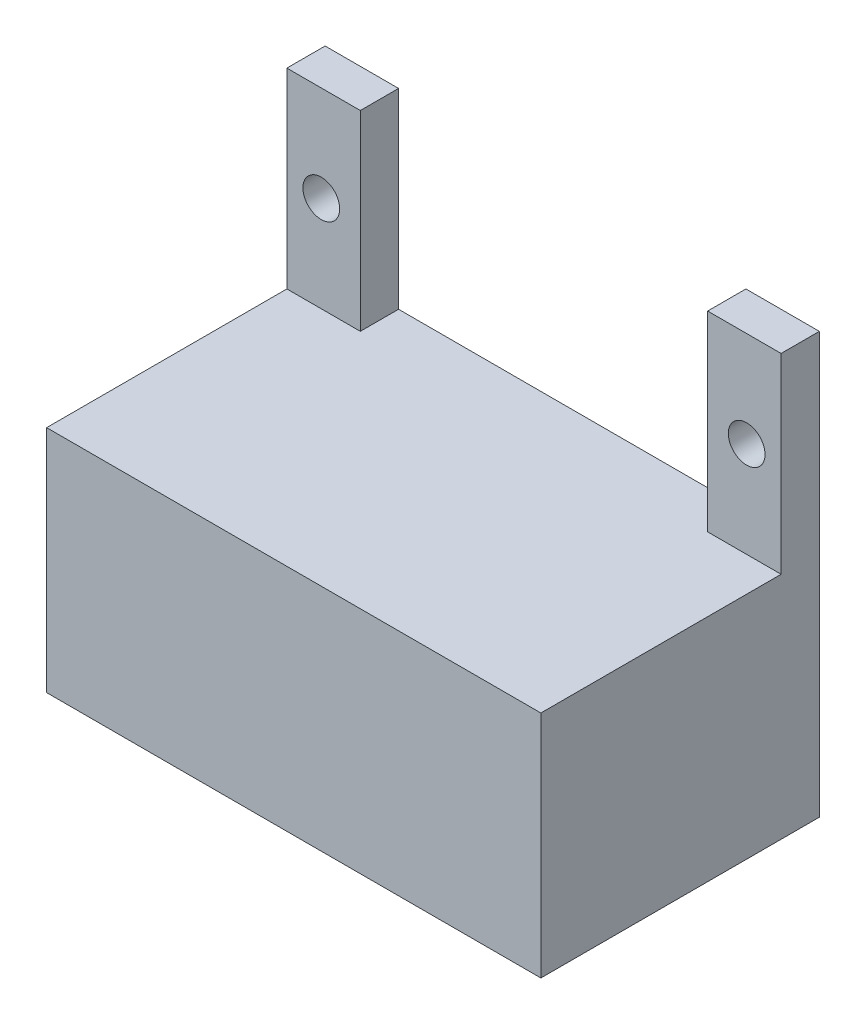
from build123d import *

# Parameters (mm, degrees)
SKETCH1_R           = 1.2
BOSS_EXTRUDE1_DEPTH = 2.5
SKETCH2_W           = 32.3
SKETCH2_H           = 15
BOSS_EXTRUDE2_DEPTH = 15.7


with BuildPart() as part:
    # Sketch1 → Boss-Extrude1 (new body)
    with BuildSketch(Plane.XY):
        Polygon((0, 0), (0, 27.5), (4.8, 27.5), (4.8, 15), (27.5, 15), (27.5, 27.5), (32.3, 27.5), (32.3, 0), align=None)
        with Locations((2.25, 21.25)):
            Circle(SKETCH1_R, mode=Mode.SUBTRACT)
        with Locations((30.05, 21.25)):
            Circle(SKETCH1_R, mode=Mode.SUBTRACT)
    extrude(amount=BOSS_EXTRUDE1_DEPTH)

    # Sketch2 → Boss-Extrude2 (add)
    with BuildSketch(Plane.XY.offset(2.5)):
        with Locations((16.15, 7.5)):
            Rectangle(SKETCH2_W, SKETCH2_H)
    extrude(amount=BOSS_EXTRUDE2_DEPTH)


solid = part.part
